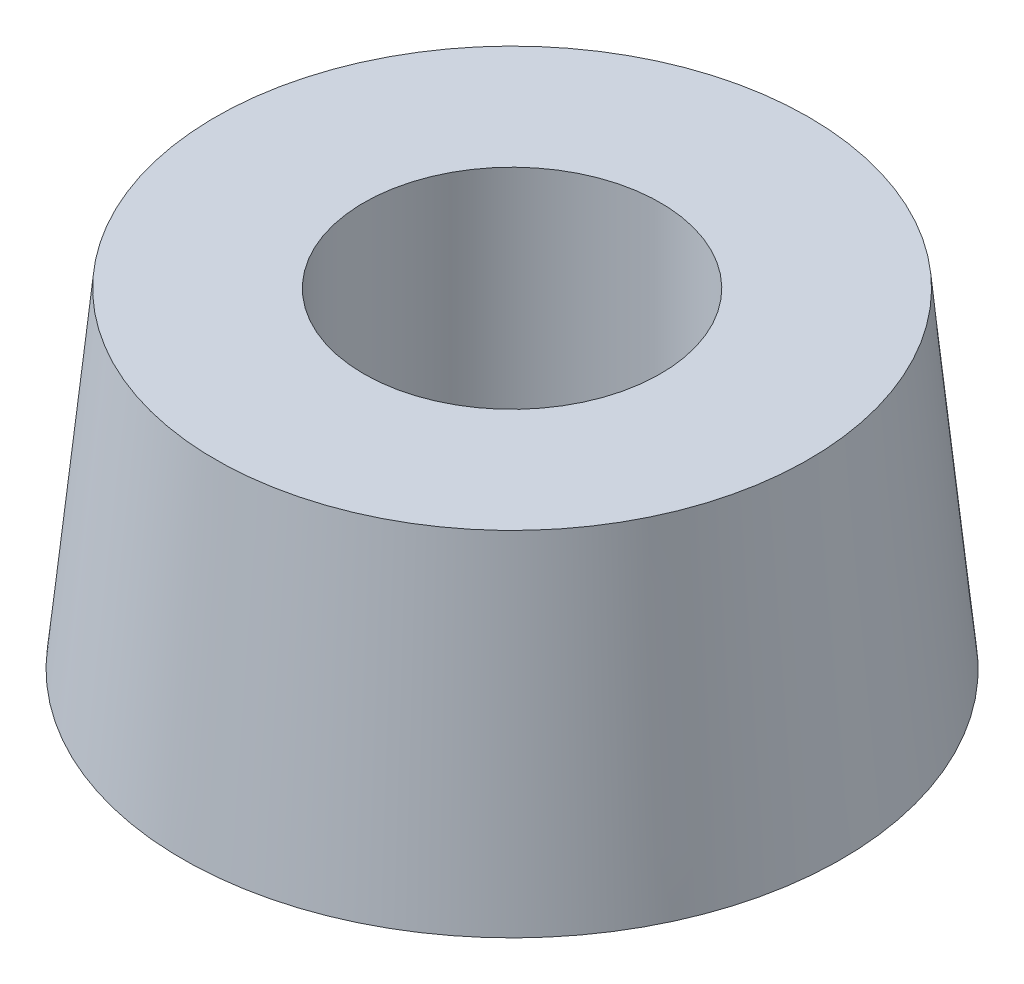
from build123d import *

# Parameters (mm, degrees)
SZKIC6_R                               = 4.5
WYTNIJ_WYCI_GNI_CIE1_DEPTH             = 6.5
WYTNIJ_WYCI_GNI_CIE2_REACH             = 5.5
SZKIC7_R                               = 2.5
WYTNIJ_WYCI_GNI_CIE2_DIRECTION_2_DEPTH = 7.5


with BuildPart() as part:
    # Szkic5 → Obrót1 (revolve)
    with BuildSketch(Plane(origin=(0, 0, 0), x_dir=(0, 0, -1), z_dir=(1, 0, 0))):
        Polygon((0, 10), (-9, 10), (-10, 0), (0, 0), align=None)
    revolve(axis=Axis((0, 0, 0), (0, 1, 0)))

    # Szkic6 → Wytnij-wyciągnięcie1 (cut)
    with BuildSketch(Plane(origin=(0, 10, 0), x_dir=(1, 0, 0), z_dir=(0, 1, 0))):
        Circle(SZKIC6_R)
    extrude(amount=-WYTNIJ_WYCI_GNI_CIE1_DEPTH, mode=Mode.SUBTRACT)

    # Szkic7 → Wytnij-wyciągnięcie2 (cut, up to next)
    with BuildSketch(Plane(origin=(0, 3.5, 0), x_dir=(1, 0, 0), z_dir=(0, 1, 0)), mode=Mode.PRIVATE) as wytnij_wyci_gni_cie2_sk1:
        Circle(SZKIC7_R)
    wytnij_wyci_gni_cie2_tool1 = extrude(wytnij_wyci_gni_cie2_sk1.sketch, amount=-WYTNIJ_WYCI_GNI_CIE2_REACH, mode=Mode.PRIVATE) & part.part
    add(wytnij_wyci_gni_cie2_tool1.solids().sort_by_distance((0, 3.5, 0))[0], mode=Mode.SUBTRACT)

    # Szkic7 → Wytnij-wyciągnięcie2 direction 2 (cut)
    with BuildSketch(Plane(origin=(0, 3.5, 0), x_dir=(1, 0, 0), z_dir=(0, 1, 0))):
        Circle(SZKIC7_R)
    extrude(amount=WYTNIJ_WYCI_GNI_CIE2_DIRECTION_2_DEPTH, mode=Mode.SUBTRACT)


solid = part.part
